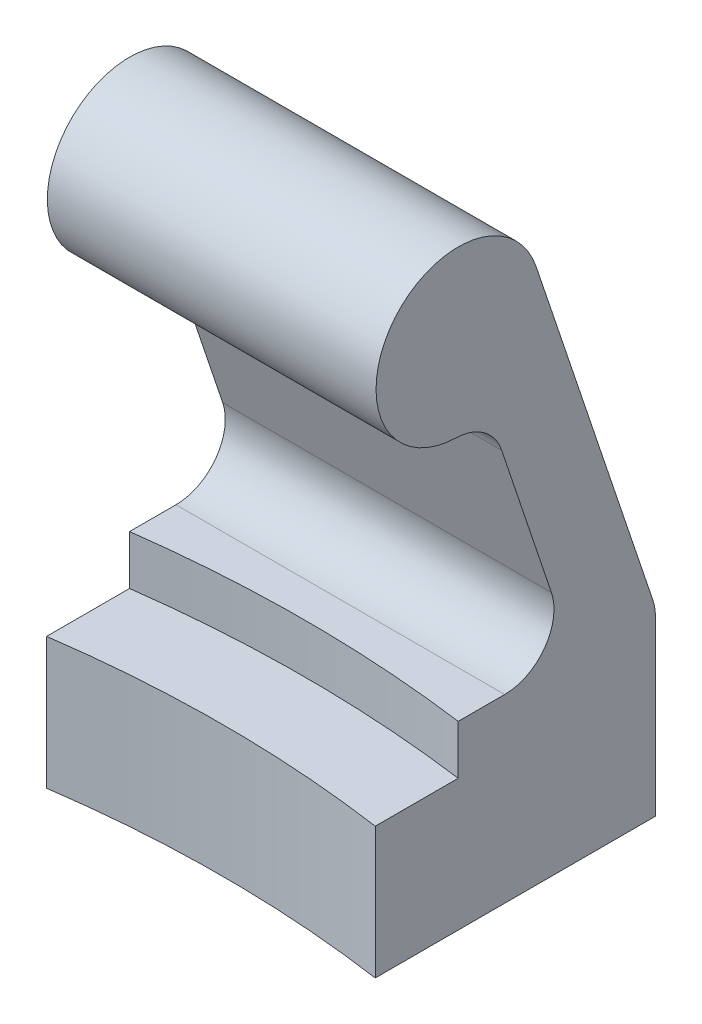
from build123d import *

# Parameters (mm, degrees)
BOSS_EXTRUDE1_DEPTH = 8
BOSS_EXTRUDE2_DEPTH = 3
BOSS_EXTRUDE3_DEPTH = 20
FILLET5_R           = 3


with BuildPart() as part:
    # Sketch1 → Boss-Extrude1 (new body)
    with BuildSketch(Plane(origin=(0, 0, 0), x_dir=(1, 0, 0), z_dir=(0, 1, 0))):
        with BuildLine():
            Line((-10, 69.282032303), (-10, 74.330343737))
            Line((-10, 74.330343737), (-10, 86.330343737))
            Line((-10, 86.330343737), (10, 86.330343737))
            Line((10, 86.330343737), (10, 74.330343737))
            Line((10, 74.330343737), (10, 69.282032303))
            ThreePointArc((10, 69.282032303), (0, 70), (-10, 69.282032303))
        make_face()
    extrude(amount=BOSS_EXTRUDE1_DEPTH)

    # Sketch2 → Boss-Extrude2 (add)
    with BuildSketch(Plane(origin=(0, 8, 0), x_dir=(1, 0, 0), z_dir=(0, 1, 0))):
        with BuildLine():
            Line((-10, 74.330343737), (-10, 86.330343737))
            Line((-10, 86.330343737), (10, 86.330343737))
            Line((10, 86.330343737), (10, 74.330343737))
            ThreePointArc((10, 74.330343737), (0, 75), (-10, 74.330343737))
        make_face()
    extrude(amount=BOSS_EXTRUDE2_DEPTH)

    # Sketch3 → Boss-Extrude3 (add)
    with BuildSketch(Plane(origin=(10, 0, 0), x_dir=(0, 0, -1), z_dir=(1, 0, 0))):
        with BuildLine():
            Line((81.330343737, 11), (86.330343737, 11))
            Line((86.330343737, 11), (79.069603203, 32.59355568))
            ThreePointArc((79.069603203, 32.59355568), (69.795873168, 33.106792981), (76.168874572, 26.350289862))
            Line((76.168874572, 26.350289862), (81.330343737, 11))
        make_face()
    extrude(amount=-BOSS_EXTRUDE3_DEPTH)

    # Fillet5
    fillet5_edges = [part.edges().sort_by_distance(p)[0] for p in [
        (0, 11, -86.330343737),
        (0, 11, -81.330343737),
        (0, 26.350289862, -76.168874572),
    ]]
    fillet(fillet5_edges, radius=FILLET5_R)


solid = part.part
